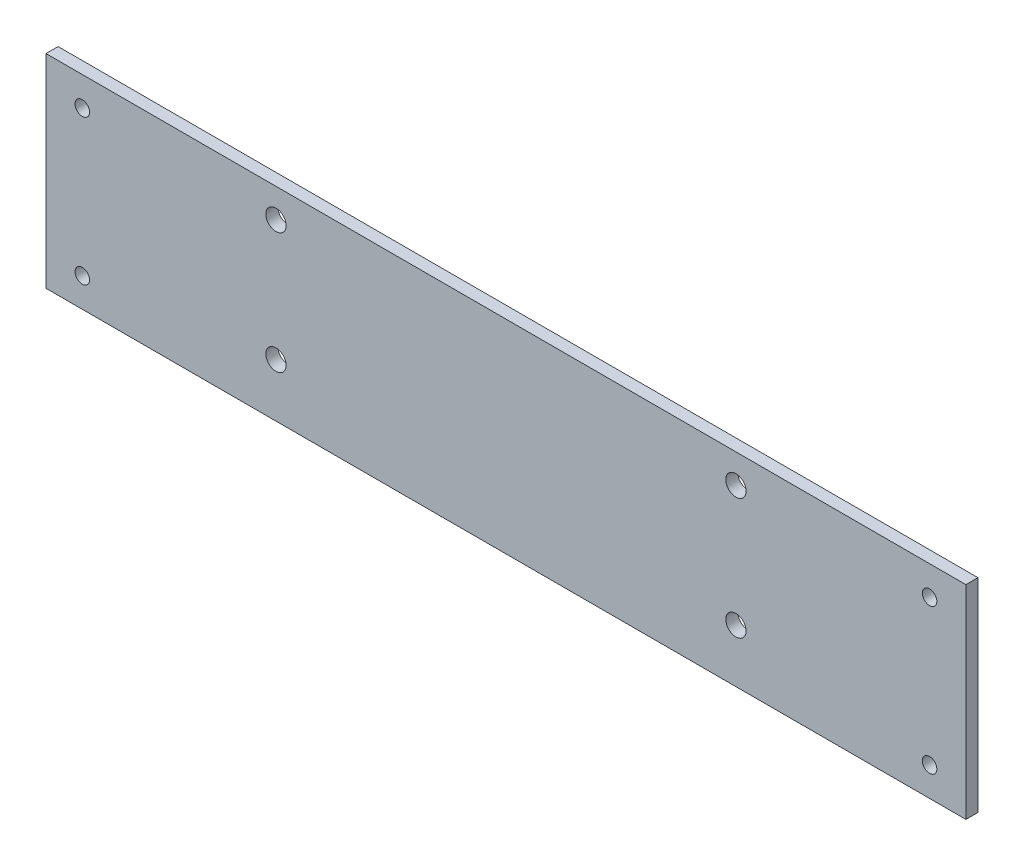
from build123d import *

# Parameters (mm, degrees)
SKETCH1_W           = 190
SKETCH1_H           = 50
BOSS_EXTRUDE1_DEPTH = 2.5
SKETCH2_R           = 1.5
CUT_EXTRUDE1_DEPTH  = 3.5
SKETCH3_R           = 2.1
CUT_EXTRUDE2_DEPTH  = 3.5
SKETCH_2_W          = 199.955047508
SKETCH_2_H          = 60.796168266
SKETCH_2_W_2        = 190
SKETCH_2_H_2        = 42
CUT_EXTRUDE_1_DEPTH = 10


with BuildPart() as part:
    # Sketch1 → Boss-Extrude1 (new body)
    with BuildSketch(Plane.XY):
        with Locations((-34.225888325, 19.067258883)):
            Rectangle(SKETCH1_W, SKETCH1_H)
    extrude(amount=BOSS_EXTRUDE1_DEPTH)

    # Sketch2 → Cut-Extrude1 (cut, through all)
    with BuildSketch(Plane.XY.offset(2.5)):
        with Locations((-121.725888325, 34.067258883)):
            Circle(SKETCH2_R)
        with Locations((-121.725888325, 4.067258883)):
            Circle(SKETCH2_R)
        with Locations((53.274111675, 34.067258883)):
            Circle(SKETCH2_R)
        with Locations((53.274111675, 4.067258883)):
            Circle(SKETCH2_R)
    extrude(amount=-CUT_EXTRUDE1_DEPTH, mode=Mode.SUBTRACT)

    # Sketch3 → Cut-Extrude2 (cut, through all)
    with BuildSketch(Plane.XY.offset(2.5)):
        with Locations((-81.725888325, 34.067258883)):
            Circle(SKETCH3_R)
        with Locations((13.274111675, 34.067258883)):
            Circle(SKETCH3_R)
        with Locations((13.274111675, 9.067258883)):
            Circle(SKETCH3_R)
        with Locations((-81.725888325, 9.067258883)):
            Circle(SKETCH3_R)
    extrude(amount=-CUT_EXTRUDE2_DEPTH, mode=Mode.SUBTRACT)

    # 草图2 → 切除-拉伸1 (cut)
    with BuildSketch(Plane.XY.offset(2.5)):
        with Locations((-32.748481011, 19.803493347)):
            Rectangle(SKETCH_2_W, SKETCH_2_H)
        with Locations((-34.225888325, 19.067258883)):
            Rectangle(SKETCH_2_W_2, SKETCH_2_H_2, mode=Mode.SUBTRACT)
    extrude(amount=-CUT_EXTRUDE_1_DEPTH, mode=Mode.SUBTRACT)


solid = part.part
